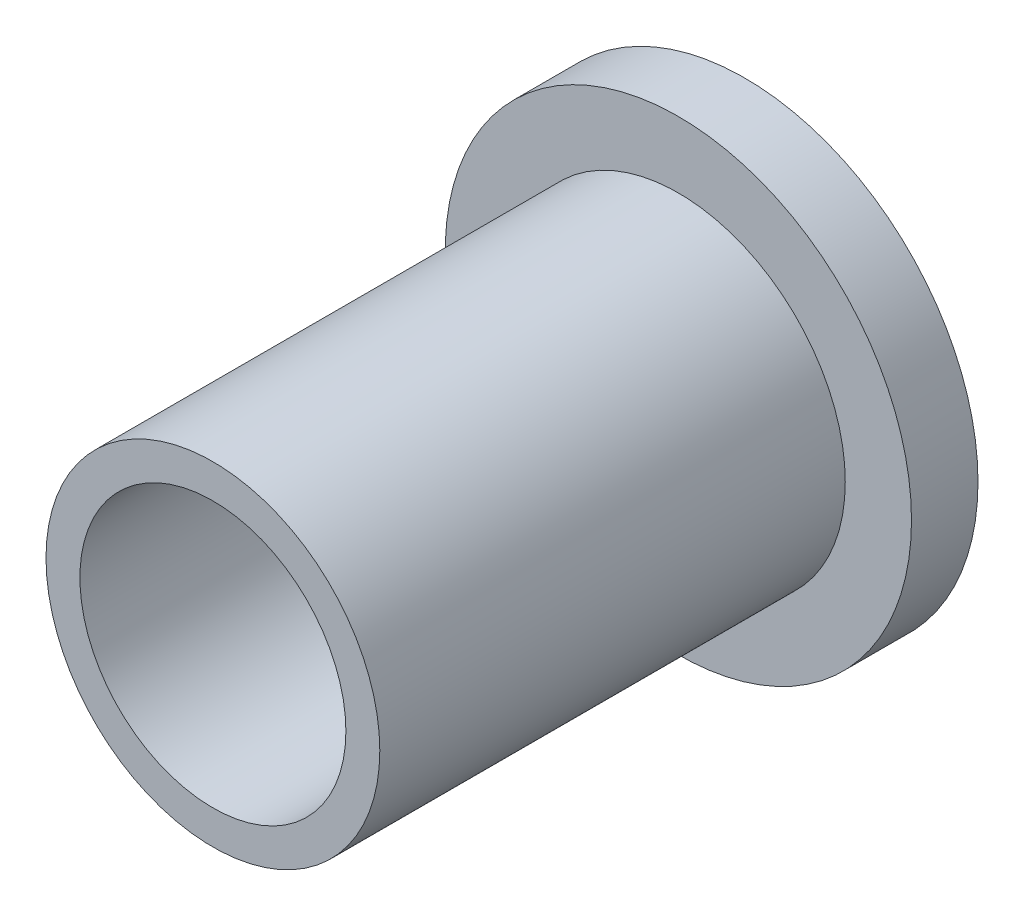
from build123d import *

# Parameters (mm, degrees)
SKETCH1_R           = 11.13155
SKETCH1_R_2         = 6.35
BOSS_EXTRUDE1_DEPTH = 3.175
SKETCH2_R           = 7.96925
SKETCH2_R_2         = 6.35
BOSS_EXTRUDE2_DEPTH = 22.225


with BuildPart() as part:
    # Sketch1 → Boss-Extrude1 (new body)
    with BuildSketch(Plane.XY):
        Circle(SKETCH1_R)
        Circle(SKETCH1_R_2, mode=Mode.SUBTRACT)
    extrude(amount=BOSS_EXTRUDE1_DEPTH)

    # Sketch2 → Boss-Extrude2 (add)
    with BuildSketch(Plane.XY.offset(3.175)):
        Circle(SKETCH2_R)
        Circle(SKETCH2_R_2, mode=Mode.SUBTRACT)
    extrude(amount=BOSS_EXTRUDE2_DEPTH)


solid = part.part
